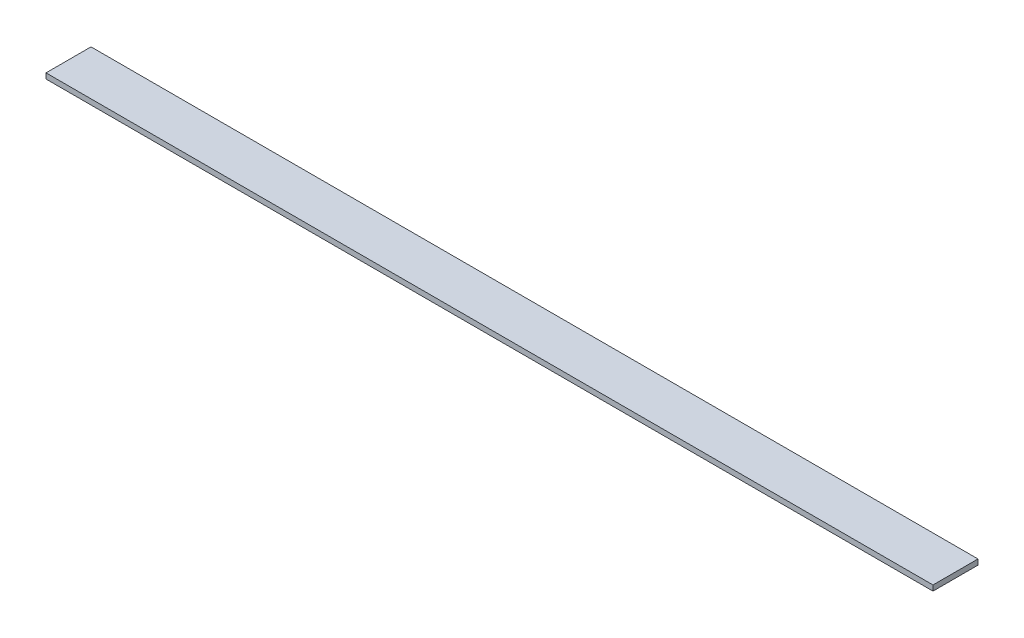
from build123d import *

# Parameters (mm, degrees)
SKETCH1_W           = 16.75
SKETCH1_H           = 2
BOSS_EXTRUDE1_DEPTH = 165


with BuildPart() as part:
    # Sketch1 → Boss-Extrude1 (new body, symmetric)
    with BuildSketch(Plane(origin=(0, 0, 0), x_dir=(0, 0, -1), z_dir=(1, 0, 0))):
        Rectangle(SKETCH1_W, SKETCH1_H)
    extrude(amount=BOSS_EXTRUDE1_DEPTH, both=True)


solid = part.part
